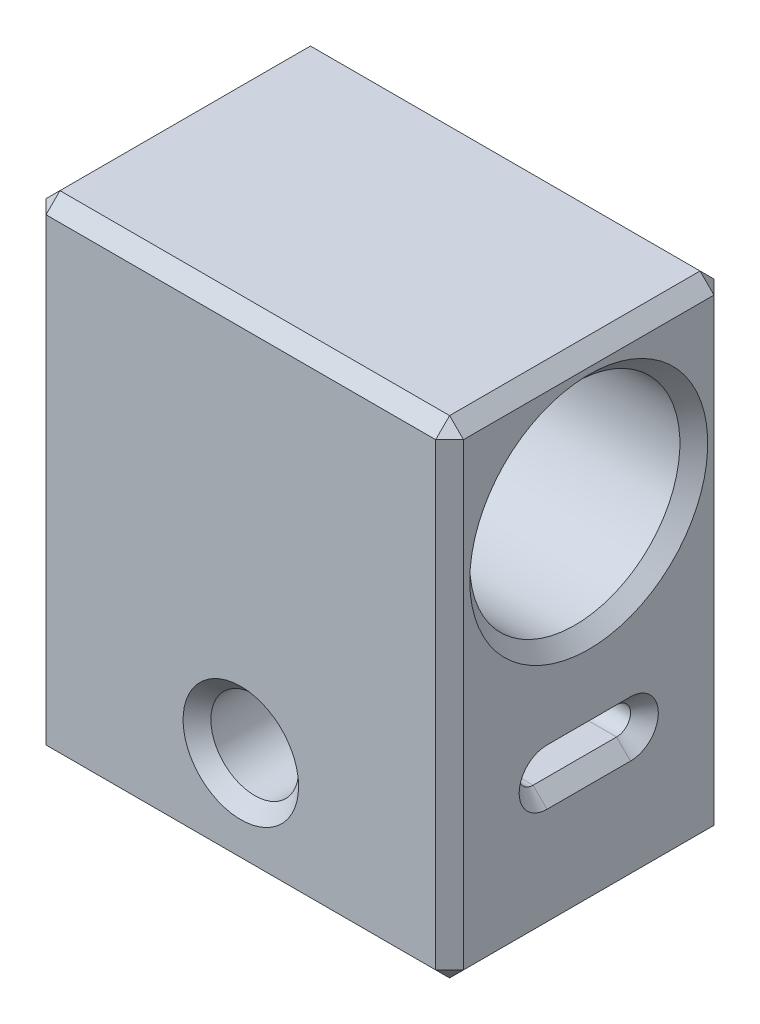
from build123d import *

# Parameters (mm, degrees)
SKETCH_1_W          = 20
SKETCH_1_H          = 35
SKETCH_1_R          = 7.55
EXTRUDE_1_DEPTH     = 30
CUT_EXTRUDE_1_REACH = 22
SKETCH_2_R          = 3.15
CUT_EXTRUDE_2_DEPTH = 10
CUT_EXTRUDE_3_DEPTH = 10
SKETCH_5_R          = 1.4
CUT_EXTRUDE_4_DEPTH = 13
CHAMFER_1_SIZE      = 1
CHAMFER_2_SIZE      = 1.5


with BuildPart() as part:
    # 草图1 → 凸台-拉伸1 (new body)
    with BuildSketch(Plane(origin=(0, 0, 0), x_dir=(0, 0, -1), z_dir=(1, 0, 0))):
        with Locations((10, 17.5)):
            Rectangle(SKETCH_1_W, SKETCH_1_H)
        with Locations((10, 25)):
            Circle(SKETCH_1_R, mode=Mode.SUBTRACT)
    extrude(amount=EXTRUDE_1_DEPTH)

    # 草图2 → 切除-拉伸1 (cut, up to next)
    with BuildSketch(Plane.XY, mode=Mode.PRIVATE) as cut_extrude_1_sk1:
        with Locations((15, 7.5)):
            Circle(SKETCH_2_R)
    cut_extrude_1_tool1 = extrude(cut_extrude_1_sk1.sketch, amount=-CUT_EXTRUDE_1_REACH, mode=Mode.PRIVATE) & part.part
    add(cut_extrude_1_tool1.solids().sort_by_distance((15, 7.5, 0))[0], mode=Mode.SUBTRACT)

    # 草图3 → 切除-拉伸2 (cut)
    with BuildSketch(Plane(origin=(30, 0, 0), x_dir=(0, 0, -1), z_dir=(1, 0, 0))):
        with BuildLine():
            Line((7, 11), (13, 11))
            ThreePointArc((13, 11), (14, 10), (13, 9))
            Line((13, 9), (7, 9))
            ThreePointArc((7, 9), (6, 10), (7, 11))
        make_face()
    extrude(amount=-CUT_EXTRUDE_2_DEPTH, mode=Mode.SUBTRACT)

    # 草图4 → 切除-拉伸3 (cut)
    with BuildSketch(Plane.ZY):
        with BuildLine():
            Line((-7, 9), (-13, 9))
            ThreePointArc((-13, 9), (-14, 10), (-13, 11))
            Line((-13, 11), (-7, 11))
            ThreePointArc((-7, 11), (-6, 10), (-7, 9))
        make_face()
    extrude(amount=-CUT_EXTRUDE_3_DEPTH, mode=Mode.SUBTRACT)

    # 草图5 → 切除-拉伸4 (cut)
    with BuildSketch(Plane.XZ):
        with Locations((5, -10)):
            Circle(SKETCH_5_R)
        with Locations((25, -10)):
            Circle(SKETCH_5_R)
    extrude(amount=-CUT_EXTRUDE_4_DEPTH, mode=Mode.SUBTRACT)

    # 倒角1
    chamfer_1_edges = [part.edges().sort_by_distance(p)[0] for p in [
        (0, 25, -2.45),
        (30, 25, -2.45),
        (30, 35, -10),
        (30, 17.5, 0),
        (11.85, 7.5, 0),
        (11.85, 7.5, -20),
        (30, 10, -6),
        (30, 9, -10),
        (30, 10, -14),
        (30, 11, -10),
        (0, 10, -6),
        (0, 11, -10),
        (0, 10, -14),
        (0, 9, -10),
        (30, 0, -10),
        (0, 17.5, 0),
        (0, 35, -10),
        (0, 17.5, -20),
        (0, 0, -10),
        (15, 0, 0),
        (15, 35, 0),
        (15, 35, -20),
        (15, 0, -20),
        (30, 17.5, -20),
    ]]
    chamfer(chamfer_1_edges, length=CHAMFER_1_SIZE)

    # 倒角2
    chamfer_2_edges = [part.edges().sort_by_distance(p)[0] for p in [
        (3.6, 0, -10),
        (23.6, 0, -10),
    ]]
    chamfer(chamfer_2_edges, length=CHAMFER_2_SIZE)


solid = part.part
